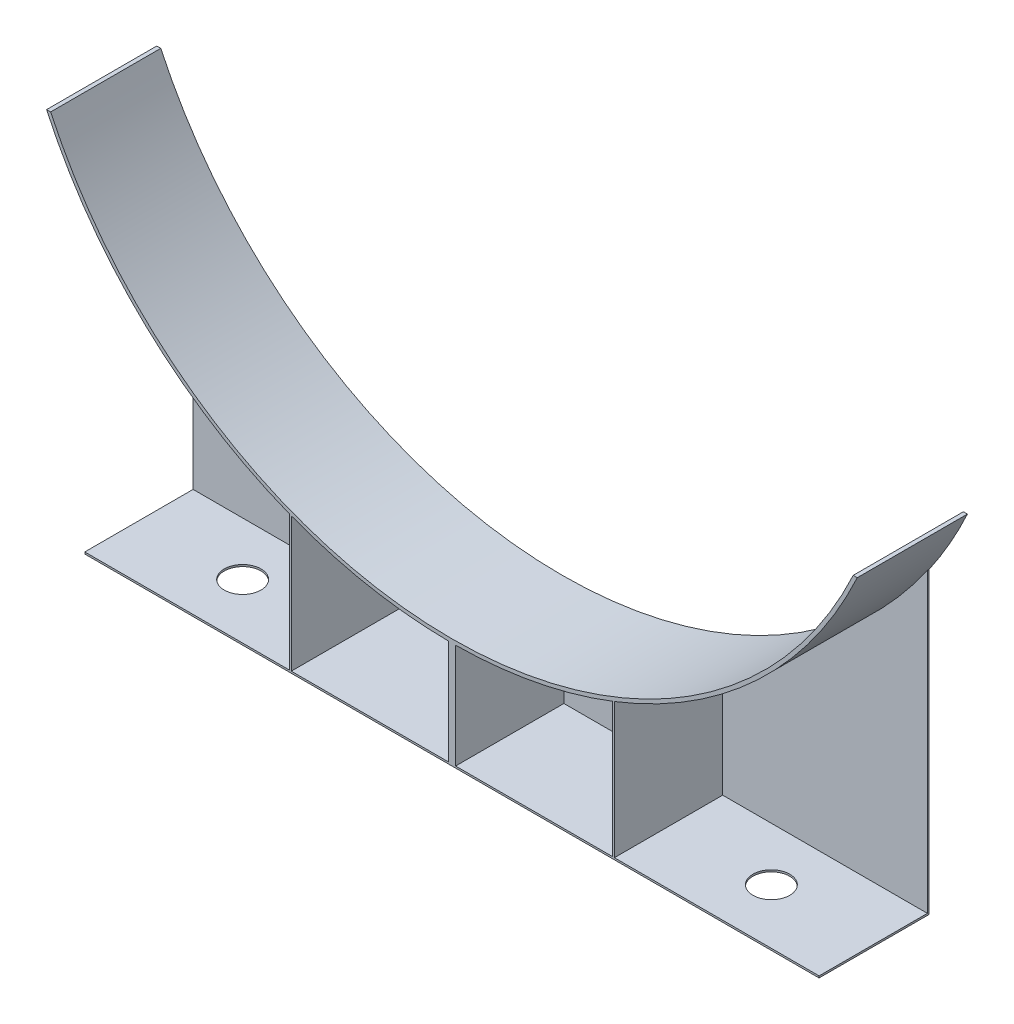
from build123d import *

# Parameters (mm, degrees)
BOSS_EXTRUDE1_DEPTH = 6
BOSS_EXTRUDE2_DEPTH = 6
BOSS_EXTRUDE3_DEPTH = 0.1
SKETCH4_W           = 40
SKETCH4_H           = 6
BOSS_EXTRUDE4_DEPTH = 0.1
SKETCH7_R           = 1
CUT_EXTRUDE1_DEPTH  = 1.1
SCALE1_SCALE        = 25.4


with BuildPart() as part:
    # Sketch1 → Boss-Extrude1 (new body)
    with BuildSketch(Plane.XY):
        with BuildLine():
            Line((21.860143823, -10.193552473), (22.080622454, -10.193552473))
            ThreePointArc((22.080622454, -10.193552473), (0, -24.32), (-22.080622454, -10.193552473))
            Line((-22.080622454, -10.193552473), (-21.860143823, -10.193552473))
            ThreePointArc((-21.860143823, -10.193552473), (0, -24.12), (21.860143823, -10.193552473))
        make_face()
    extrude(amount=BOSS_EXTRUDE1_DEPTH)

    # Sketch2 → Boss-Extrude2 (add)
    with BuildSketch(Plane.XY):
        with BuildLine():
            Line((-0.2, -30.12), (0.2, -30.12))
            Line((0.2, -30.12), (0.2, -24.319177618))
            ThreePointArc((0.2, -24.319177618), (0, -24.32), (-0.2, -24.319177618))
            Line((-0.2, -24.319177618), (-0.2, -30.12))
        make_face()
        with BuildLine():
            Line((8.75, -30.12), (8.85, -30.12))
            Line((8.85, -30.12), (8.85, -22.652591463))
            ThreePointArc((8.85, -22.652591463), (8.8000214, -22.672053797), (8.75, -22.691405862))
            Line((8.75, -22.691405862), (8.75, -30.12))
        make_face()
        with BuildLine():
            Line((-8.75, -30.12), (-8.85, -30.12))
            Line((-8.85, -30.12), (-8.85, -22.652591463))
            ThreePointArc((-8.85, -22.652591463), (-8.8000214, -22.672053797), (-8.75, -22.691405862))
            Line((-8.75, -22.691405862), (-8.75, -30.12))
        make_face()
    extrude(amount=BOSS_EXTRUDE2_DEPTH)

    # Sketch3 → Boss-Extrude3 (add)
    with BuildSketch(Plane.XY):
        with BuildLine():
            Line((0, -30.12), (-20, -30.12))
            Line((-20, -30.12), (-20, -13.836993893))
            ThreePointArc((-20, -13.836993893), (0, -24.32), (20, -13.836993893))
            Line((20, -13.836993893), (20, -30.12))
            Line((20, -30.12), (0, -30.12))
        make_face()
    extrude(amount=BOSS_EXTRUDE3_DEPTH)

    # Sketch4 → Boss-Extrude4 (add)
    with BuildSketch(Plane(origin=(0, -30.12, 0), x_dir=(-1, 0, 0), z_dir=(0, -1, 0))):
        with Locations((0, -3)):
            Rectangle(SKETCH4_W, SKETCH4_H)
    extrude(amount=-BOSS_EXTRUDE4_DEPTH)

    # Sketch7 → Cut-Extrude1 (cut)
    with BuildSketch(Plane(origin=(0, -30.12, 0), x_dir=(-1, 0, 0), z_dir=(0, -1, 0))):
        with Locations((-14.4, -3)):
            Circle(SKETCH7_R)
        with Locations((14.4, -3)):
            Circle(SKETCH7_R)
    extrude(amount=-CUT_EXTRUDE1_DEPTH, mode=Mode.SUBTRACT)


with BuildPart() as part_1:
    # Scale1: scaled about (0, -23.561684395, 2.298462584)
    add(part.part.scale(SCALE1_SCALE).moved(Location((0, 574.905099238, -56.08248705))))


solid = part_1.part
